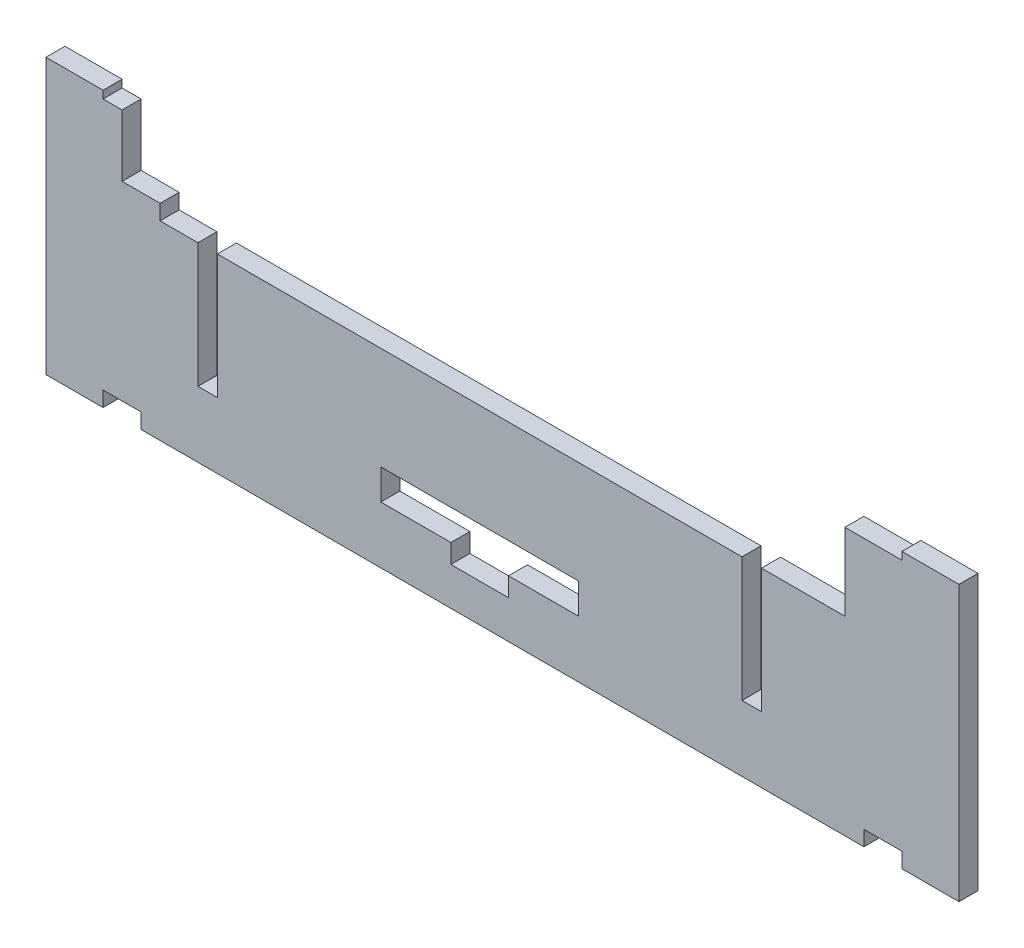
from build123d import *

# Parameters (mm, degrees)
BOSS_EXTRUDE1_DEPTH = 5
CUT_EXTRUDE6_DEPTH  = 32.7
CUT_EXTRUDE7_DEPTH  = 32.7
CUT_EXTRUDE8_DEPTH  = 50
SKETCH10_W          = 10
SKETCH10_H          = 4
CUT_EXTRUDE9_DEPTH  = 6


with BuildPart() as part:
    # Sketch1 → Boss-Extrude1 (new body)
    with BuildSketch(Plane.XY):
        Polygon((0, 0), (240, 0), (240, 72.25), (225, 72.25), (225, 70.25), (210, 70.25), (210, 54), (210, 50), (30, 50), (30, 54), (20, 54), (20, 70.25), (15, 70.25), (15, 72.25), (0, 72.25), align=None)
    extrude(amount=BOSS_EXTRUDE1_DEPTH)

    # Sketch7 → Cut-Extrude6 (cut)
    with BuildSketch(Plane(origin=(76.962340789, 50, 79.982193432), x_dir=(0.299340075, 0, -0.954146488), z_dir=(0, -1, 0))):
        Polygon((89.56567359, 88.367941315), (121.015834787, 78.501224076), (119.481716905, 73.611223328), (88.031555708, 83.477940566), align=None)
    extrude(amount=CUT_EXTRUDE6_DEPTH, mode=Mode.SUBTRACT)

    # Sketch8 → Cut-Extrude7 (cut)
    with BuildSketch(Plane(origin=(151.064056229, 50, -36.816333928), x_dir=(-0.299340075, 0, 0.954146488), z_dir=(0, -1, 0))):
        Polygon((48.269879058, 101.323484697), (121.015834787, 78.501224076), (119.481716905, 73.611223328), (46.735761176, 96.433483948), align=None)
    extrude(amount=CUT_EXTRUDE7_DEPTH, mode=Mode.SUBTRACT)

    # Sketch9 → Cut-Extrude8 (cut)
    with BuildSketch(Plane(origin=(179.822929518, 98.166866164, 0), x_dir=(-1, 0, 0), z_dir=(0, 0, -1))):
        Polygon((91.809731009, -83.166866164), (73.384731009, -83.166866164), (73.384731009, -88.166866164), (58.234731009, -88.166866164), (58.234731009, -83.166866164), (39.809731009, -83.166866164), (39.809731009, -75.166866164), (91.809731009, -75.166866164), align=None)
    extrude(amount=-CUT_EXTRUDE8_DEPTH, mode=Mode.SUBTRACT)

    # Sketch10 → Cut-Extrude9 (cut, through all)
    with BuildSketch(Plane.XY.offset(5)):
        with Locations((20, 2)):
            Rectangle(SKETCH10_W, SKETCH10_H)
        with Locations((220, 2)):
            Rectangle(SKETCH10_W, SKETCH10_H)
    extrude(amount=-CUT_EXTRUDE9_DEPTH, mode=Mode.SUBTRACT)


solid = part.part
